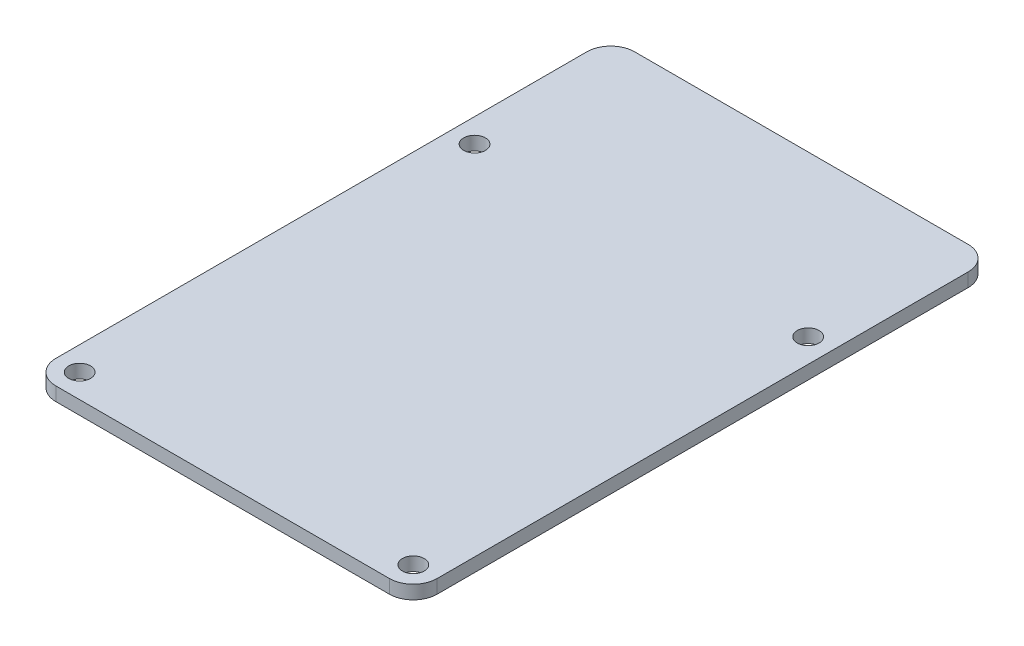
from build123d import *

# Parameters (mm, degrees)
SKETCH1_W                = 56
SKETCH1_H                = 85
BOSS_EXTRUDE1_DEPTH      = 2
M3_CLEARANCE_HOLE1_D     = 3.2
M3_CLEARANCE_HOLE1_DEPTH = 2
VERRUNDUNG1_R            = 3.5


with BuildPart() as part:
    # Sketch1 → Boss-Extrude1 (new body)
    with BuildSketch(Plane(origin=(0, 0, 0), x_dir=(1, 0, 0), z_dir=(0, 1, 0))):
        Rectangle(SKETCH1_W, SKETCH1_H)
    extrude(amount=BOSS_EXTRUDE1_DEPTH)

    # M3 Clearance Hole1
    with Locations(Plane(origin=(0, 2, 0), x_dir=(1, 0, 0), z_dir=(0, 1, 0))):
        with Locations((-24.5, 19), (24.5, -39), (-24.5, -39), (24.5, 19)):
            Hole(M3_CLEARANCE_HOLE1_D / 2, depth=M3_CLEARANCE_HOLE1_DEPTH)

    # Verrundung1
    verrundung1_edges = [part.edges().sort_by_distance(p)[0] for p in [
        (28, 1, 42.5),
        (-28, 1, 42.5),
        (-28, 1, -42.5),
        (28, 1, -42.5),
    ]]
    fillet(verrundung1_edges, radius=VERRUNDUNG1_R)


solid = part.part
